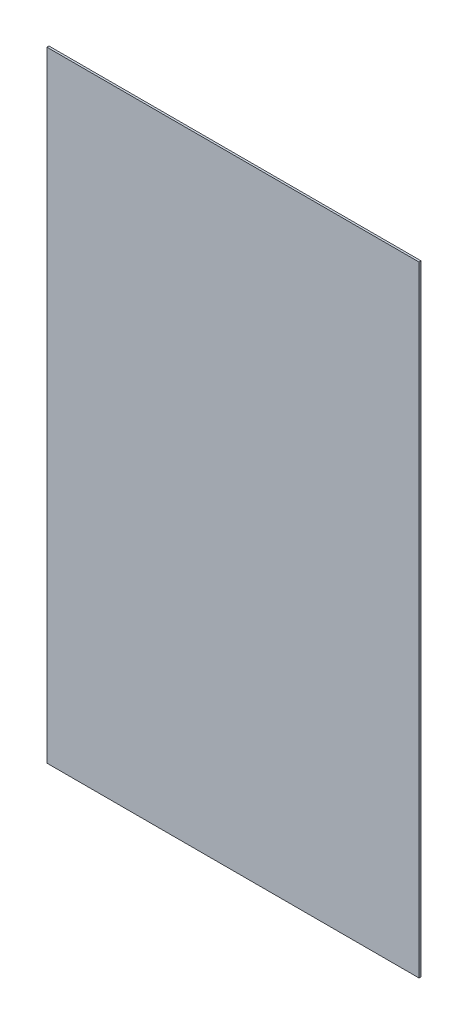
from build123d import *

# Parameters (mm, degrees)
SKETCH_1_W      = 18
SKETCH_1_H      = 30
EXTRUDE_1_DEPTH = 0.1


with BuildPart() as part:
    # 草图1 → 凸台-拉伸1 (new body)
    with BuildSketch(Plane.XY):
        Rectangle(SKETCH_1_W, SKETCH_1_H)
    extrude(amount=EXTRUDE_1_DEPTH)


solid = part.part
